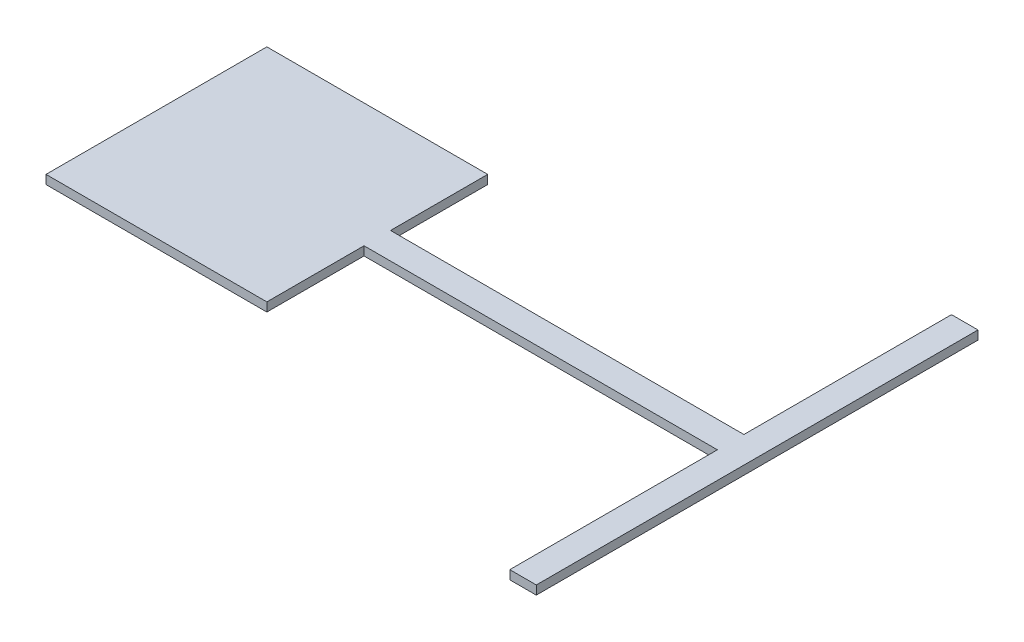
from build123d import *

# Parameters (mm, degrees)
SKETCH1_W           = 250
SKETCH1_H           = 250
SKETCH1_W_2         = 400
SKETCH1_H_2         = 30
BOSS_EXTRUDE1_DEPTH = 10


with BuildPart() as part:
    # Sketch1 → Boss-Extrude1 (new body)
    with BuildSketch(Plane(origin=(0, 0, 0), x_dir=(1, 0, 0), z_dir=(0, 1, 0))):
        with Locations((-197.674418605, 16.472868217)):
            Rectangle(SKETCH1_W, SKETCH1_H)
        with Locations((127.325581395, 16.472868217)):
            Rectangle(SKETCH1_W_2, SKETCH1_H_2)
        Polygon((327.325581395, 266.472868217), (327.325581395, 31.472868217), (327.325581395, 1.472868217), (327.325581395, -233.527131783), (357.325581395, -233.527131783), (357.325581395, 266.472868217), align=None)
    extrude(amount=BOSS_EXTRUDE1_DEPTH)


solid = part.part
